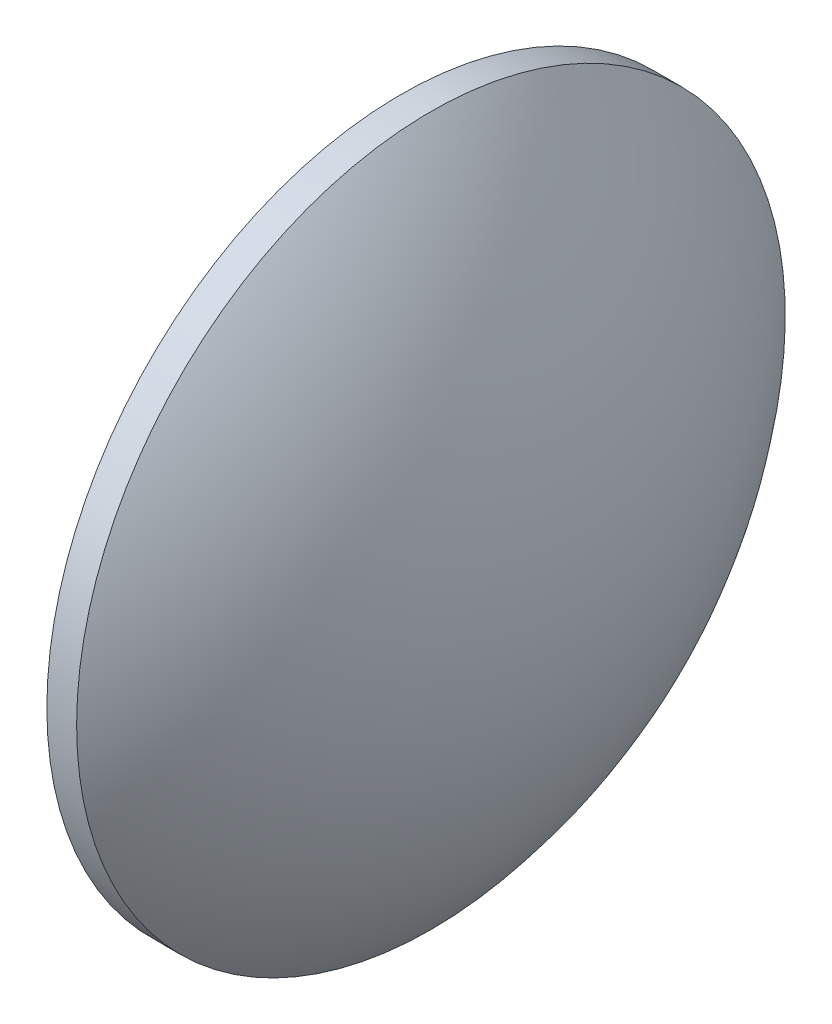
from build123d import *


with BuildPart() as part:
    # 草图1 → 旋转1 (revolve)
    with BuildSketch(Plane.XY, mode=Mode.PRIVATE) as revolve_1_sk:
        with BuildLine():
            Line((441.519907838, 82.59863874), (441.519907838, 92.59863874))
            Line((441.519907838, 92.59863874), (442.359907838, 92.59863874))
            ThreePointArc((442.359907838, 92.59863874), (445.07616059, 87.923007247), (446.019907838, 82.59863874))
            Line((446.019907838, 82.59863874), (441.519907838, 82.59863874))
        make_face()
    revolve(revolve_1_sk.sketch.rotate(Axis((439.896621775, 82.59863874, 0), (1, 0, 0)), 180), axis=Axis((439.896621775, 82.59863874, 0), (1, 0, 0)))  # turned: the seam where the file's is


solid = part.part
